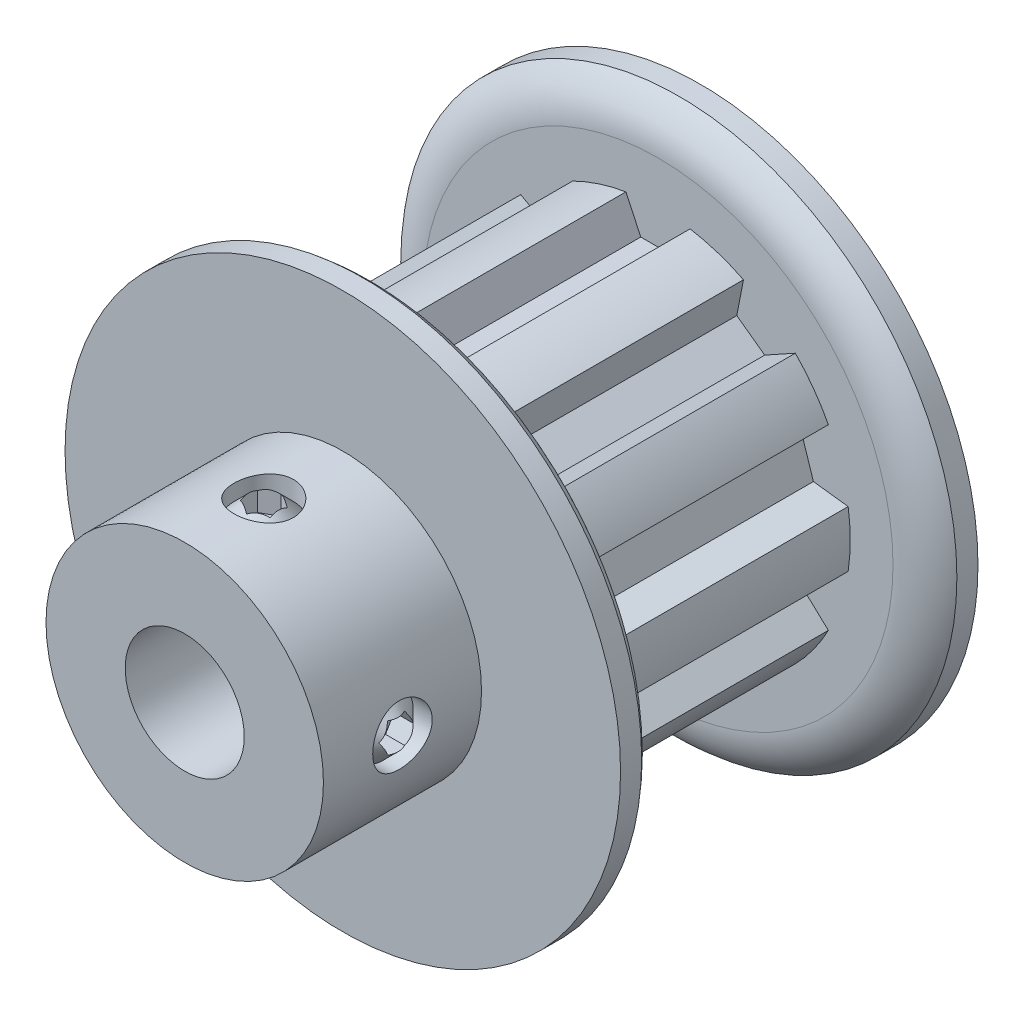
from build123d import *

# Parameters (mm, degrees)
CUT_EXTRUDE1_START = 2.2987
CUT_EXTRUDE1_DEPTH = 10.922
CIRPATTERN1_COUNT  = 10
SKETCH4_R          = 1.190625
CUT_EXTRUDE2_DEPTH = 19.796832346
CUT_EXTRUDE3_DEPTH = 0.89296875
CIRPATTERN2_COUNT  = 2
CIRPATTERN2_ANGLE  = 90


with BuildPart() as part:
    # Sketch2 → Revolve1 (revolve)
    with BuildSketch(Plane(origin=(0, 0, 0), x_dir=(0, 0, -1), z_dir=(1, 0, 0)), mode=Mode.PRIVATE) as revolve1_sk:
        with BuildLine():
            Line((-10.3124, 2.38125), (10.3124, 2.38125))
            Line((10.3124, 2.38125), (10.3124, 11.1125))
            Line((10.3124, 11.1125), (9.46785, 11.1125))
            ThreePointArc((9.46785, 11.1125), (8.84593021, 10.355304295), (8.6233, 9.401068816))
            Line((8.6233, 9.401068816), (8.6233, 7.689637631))
            Line((8.6233, 7.689637631), (-2.2987, 7.689637631))
            Line((-2.2987, 7.689637631), (-2.2987, 9.401068816))
            ThreePointArc((-2.2987, 9.401068816), (-2.52133021, 10.355304295), (-3.14325, 11.1125))
            Line((-3.14325, 11.1125), (-3.9878, 11.1125))
            Line((-3.9878, 11.1125), (-3.9878, 5.5499))
            Line((-3.9878, 5.5499), (-10.3124, 5.5499))
            Line((-10.3124, 5.5499), (-10.3124, 2.38125))
        make_face()
    revolve(revolve1_sk.sketch.rotate(Axis((0, 0, 10.3124), (0, 0, -1)), 90), axis=Axis((0, 0, 10.3124), (0, 0, -1)))

    # Sketch3 → Cut-Extrude1 (cut)
    with BuildSketch(Plane.XY.offset(CUT_EXTRUDE1_START)):
        with BuildLine():
            Line((-0.690489274, 6.3119), (0.690489274, 6.3119))
            Line((0.690489274, 6.3119), (1.2827, 7.5819))
            ThreePointArc((1.2827, 7.5819), (0, 7.689637631), (-1.2827, 7.5819))
            Line((-1.2827, 7.5819), (-0.690489274, 6.3119))
        make_face()
    cut_extrude1 = extrude(amount=-CUT_EXTRUDE1_DEPTH, mode=Mode.SUBTRACT)

    # CirPattern1: Cut-Extrude1 ×10 about axis
    cirpattern1_axis = Axis((0, 0, 0), (0, 0, 1))
    for i in range(1, CIRPATTERN1_COUNT):
        add(cut_extrude1.rotate(cirpattern1_axis, i * 360 / CIRPATTERN1_COUNT), mode=Mode.SUBTRACT)

    # Sketch4 → Cut-Extrude2 (cut, through all)
    with BuildSketch(Plane(origin=(0, 0, 0), x_dir=(1, 0, 0), z_dir=(0, 1, 0))):
        with Locations(Location((0, -7.1501, 0), (0, 0, 90))):
            Circle(SKETCH4_R)
    cut_extrude2 = extrude(amount=CUT_EXTRUDE2_DEPTH, mode=Mode.SUBTRACT)

    # Sketch5 → Revolve2 (revolve)
    with BuildSketch(Plane.XY.offset(7.1501), mode=Mode.PRIVATE) as revolve2_sk:
        Polygon((0, 5.420682809), (0, 2.38125), (-0.555625, 2.38125), (-1.190625, 3.01625), (-1.190625, 4.785682809), (-0.555625, 5.420682809), align=None)
    revolve2 = revolve(revolve2_sk.sketch.rotate(Axis((0, 0, 7.1501), (0, 1, 0)), 270), axis=Axis((0, 0, 7.1501), (0, 1, 0)))

    # Sketch6 → Cut-Extrude3 (cut)
    with BuildSketch(Plane(origin=(0, 5.420682809, 0), x_dir=(-1, 0, 0), z_dir=(0, -1, 0))):
        Polygon((0, -6.462692336), (-0.5953125, -6.806396168), (-0.5953125, -7.493803832), (0, -7.837507664), (0.5953125, -7.493803832), (0.5953125, -6.806396168), align=None)
    cut_extrude3 = extrude(amount=CUT_EXTRUDE3_DEPTH, mode=Mode.SUBTRACT)

    # CirPattern2: Cut-Extrude2, Revolve2, Cut-Extrude3 ×2 about axis
    cirpattern2_axis = Axis((0, 0, 0), (0, 0, -1))
    add([cut_extrude2.rotate(cirpattern2_axis, i * CIRPATTERN2_ANGLE / (CIRPATTERN2_COUNT - 1)) for i in range(1, CIRPATTERN2_COUNT)], mode=Mode.SUBTRACT)
    add([revolve2.rotate(cirpattern2_axis, i * CIRPATTERN2_ANGLE / (CIRPATTERN2_COUNT - 1)) for i in range(1, CIRPATTERN2_COUNT)])
    add([cut_extrude3.rotate(cirpattern2_axis, i * CIRPATTERN2_ANGLE / (CIRPATTERN2_COUNT - 1)) for i in range(1, CIRPATTERN2_COUNT)], mode=Mode.SUBTRACT)


solid = part.part
